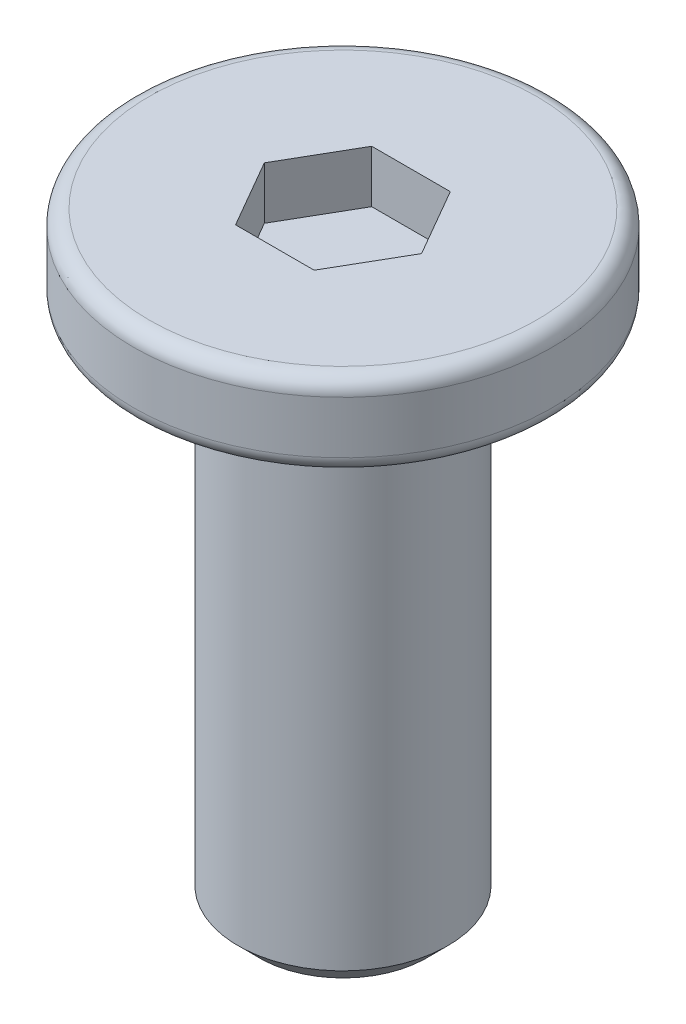
from build123d import *

# Parameters (mm, degrees)
SKETCH_1_R          = 2
EXTRUDE_1_DEPTH     = 0.8
SKETCH_2_R          = 1
EXTRUDE_2_DEPTH     = 5
FILLET_1_R          = 0.15
CHAMFER_1_SIZE      = 0.2
CUT_EXTRUDE_1_DEPTH = 0.5


with BuildPart() as part:
    # 草图1 → 凸台-拉伸1 (new body)
    with BuildSketch(Plane(origin=(0, 0, 0), x_dir=(1, 0, 0), z_dir=(0, 1, 0))):
        Circle(SKETCH_1_R)
    extrude(amount=EXTRUDE_1_DEPTH)

    # 草图2 → 凸台-拉伸2 (add)
    with BuildSketch(Plane.XZ):
        Circle(SKETCH_2_R)
    extrude(amount=EXTRUDE_2_DEPTH)

    # 圆角1
    fillet_1_edges = [part.edges().sort_by_distance(p)[0] for p in [
        (-2, 0, 0),
        (-2, 0.8, 0),
    ]]
    fillet(fillet_1_edges, radius=FILLET_1_R)

    # 倒角1
    chamfer_1_edges = [part.edges().sort_by_distance(p)[0] for p in [
        (-1, -5, 0),
    ]]
    chamfer(chamfer_1_edges, length=CHAMFER_1_SIZE)

    # 草图3 → 切除-拉伸1 (cut)
    with BuildSketch(Plane(origin=(0, 0.8, 0), x_dir=(1, 0, 0), z_dir=(0, 1, 0))):
        Polygon((0.75055535, 0), (0.375277675, 0.65), (-0.375277675, 0.65), (-0.75055535, 0), (-0.375277675, -0.65), (0.375277675, -0.65), align=None)
    extrude(amount=-CUT_EXTRUDE_1_DEPTH, mode=Mode.SUBTRACT)


solid = part.part
